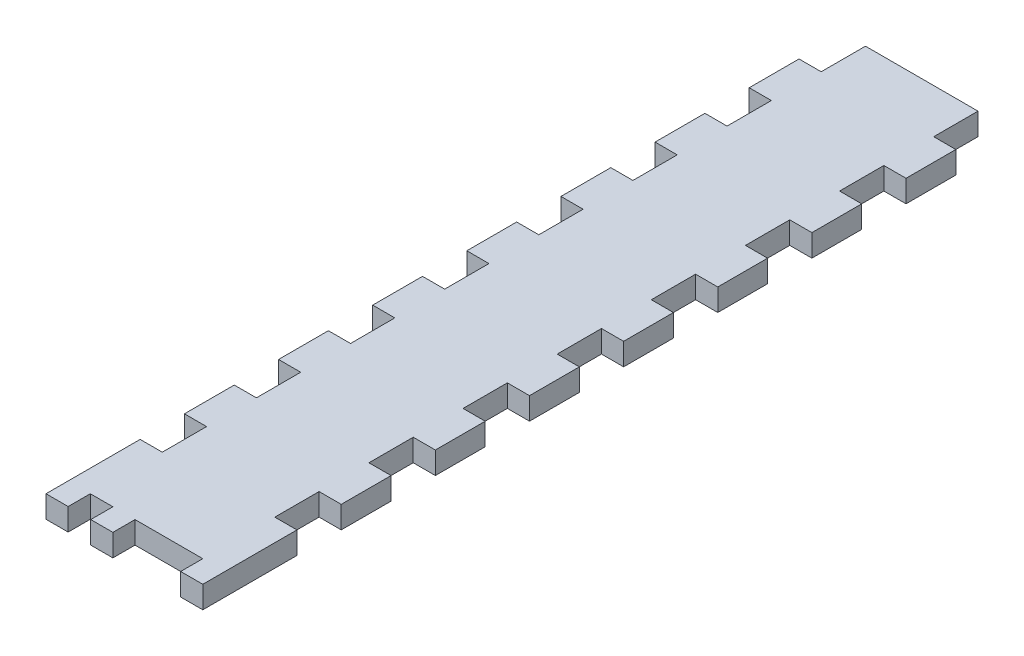
from build123d import *

# Parameters (mm, degrees)
SKETCH1_W           = 44.958
SKETCH1_H           = 304.8
BOSS_EXTRUDE1_DEPTH = 6.35
SKETCH2_W           = 6.35
SKETCH2_H           = 101.6
BOSS_EXTRUDE2_DEPTH = 6.35
SKETCH3_W           = 222.25
SKETCH3_H           = 6.35
BOSS_EXTRUDE3_DEPTH = 38.608
SKETCH7_W           = 333.372738736
SKETCH7_H           = 323.725005723
CUT_EXTRUDE1_DEPTH  = 45.958
SKETCH4_W           = 6.35
SKETCH4_H           = 12.7
CUT_EXTRUDE2_DEPTH  = 6.35
SKETCH8_W           = 6.477
SKETCH8_H           = 6.35
SKETCH8_W_2         = 19.431
CUT_EXTRUDE4_DEPTH  = 7.35


with BuildPart() as part:
    # Sketch1 → Boss-Extrude1 (new body)
    with BuildSketch(Plane.XY):
        with Locations((-6.477, 3.048)):
            Rectangle(SKETCH1_W, SKETCH1_H)
        with BuildLine():
            Line((-3.302, 133.858), (-3.302, -143.002))
            Line((-3.302, -143.002), (3.302, -143.002))
            Line((3.302, -143.002), (3.302, 143.002))
            Line((3.302, 143.002), (-16.256, 143.002))
            Line((-16.256, 143.002), (-16.256, 136.398))
            Line((-16.256, 136.398), (-5.842, 136.398))
            ThreePointArc((-5.842, 136.398), (-4.045948776, 135.654051224), (-3.302, 133.858))
        make_face(mode=Mode.SUBTRACT)
    extrude(amount=BOSS_EXTRUDE1_DEPTH)

    # Sketch2 → Boss-Extrude2 (add)
    with BuildSketch(Plane(origin=(16.002, 0, 0), x_dir=(0, 0, -1), z_dir=(1, 0, 0))):
        Polygon((222.25, -60.452), (222.25, -47.752), (0, -47.752), (0, -149.352), (222.25, -149.352), (222.25, -136.652), (228.6, -136.652), (228.6, -119.718666667), (222.25, -119.718666667), (222.25, -107.018666667), (228.6, -107.018666667), (228.6, -90.085333333), (222.25, -90.085333333), (222.25, -77.385333333), (228.6, -77.385333333), (228.6, -60.452), align=None)
        with BuildLine():
            ThreePointArc((11.4, -116.592), (9.9, -118.092), (8.4, -116.592))
            Line((8.4, -116.592), (8.4, -111.512))
            ThreePointArc((8.4, -111.512), (9.9, -110.012), (11.4, -111.512))
            Line((11.4, -111.512), (11.4, -116.592))
        make_face(mode=Mode.SUBTRACT)
        with BuildLine():
            Line((42.4, -111.512), (42.4, -116.592))
            ThreePointArc((42.4, -116.592), (40.9, -118.092), (39.4, -116.592))
            Line((39.4, -116.592), (39.4, -111.512))
            ThreePointArc((39.4, -111.512), (40.9, -110.012), (42.4, -111.512))
        make_face(mode=Mode.SUBTRACT)
        with BuildLine():
            ThreePointArc((36.4, -101.092), (25.4, -112.092), (14.4, -101.092))
            Line((14.4, -101.092), (14.4, -96.012))
            ThreePointArc((14.4, -96.012), (25.4, -85.012), (36.4, -96.012))
            Line((36.4, -96.012), (36.4, -101.092))
        make_face(mode=Mode.SUBTRACT)
        with BuildLine():
            ThreePointArc((11.4, -85.592), (9.9, -87.092), (8.4, -85.592))
            Line((8.4, -85.592), (8.4, -80.512))
            ThreePointArc((8.4, -80.512), (9.9, -79.012), (11.4, -80.512))
            Line((11.4, -80.512), (11.4, -85.592))
        make_face(mode=Mode.SUBTRACT)
        with BuildLine():
            ThreePointArc((42.4, -85.592), (40.9, -87.092), (39.4, -85.592))
            Line((39.4, -85.592), (39.4, -80.512))
            ThreePointArc((39.4, -80.512), (40.9, -79.012), (42.4, -80.512))
            Line((42.4, -80.512), (42.4, -85.592))
        make_face(mode=Mode.SUBTRACT)
        with Locations((-3.175, -98.552)):
            Rectangle(SKETCH2_W, SKETCH2_H)
    extrude(amount=-BOSS_EXTRUDE2_DEPTH)

    # Sketch3 → Boss-Extrude3 (add)
    with BuildSketch(Plane.ZY.offset(-9.652)):
        with Locations((-111.125, -146.177)):
            Rectangle(SKETCH3_W, SKETCH3_H)
    extrude(amount=BOSS_EXTRUDE3_DEPTH)

    # Sketch7 → Cut-Extrude1 (cut, through all)
    with BuildSketch(Plane(origin=(16.002, 0, 0), x_dir=(0, 0, -1), z_dir=(1, 0, 0))):
        with Locations((160.336369368, 18.860502861)):
            Rectangle(SKETCH7_W, SKETCH7_H)
    extrude(amount=-CUT_EXTRUDE1_DEPTH, mode=Mode.SUBTRACT)

    # Sketch4 → Cut-Extrude2 (cut)
    with BuildSketch(Plane.XZ.offset(149.352)):
        with Locations((12.827, -26.9875)):
            Rectangle(SKETCH4_W, SKETCH4_H)
        with Locations((-25.781, -26.9875)):
            Rectangle(SKETCH4_W, SKETCH4_H)
        with Locations((-25.781, -53.975)):
            Rectangle(SKETCH4_W, SKETCH4_H)
        with Locations((-25.781, -80.9625)):
            Rectangle(SKETCH4_W, SKETCH4_H)
        with Locations((-25.781, -107.95)):
            Rectangle(SKETCH4_W, SKETCH4_H)
        with Locations((-25.781, -134.9375)):
            Rectangle(SKETCH4_W, SKETCH4_H)
        with Locations((-25.781, -161.925)):
            Rectangle(SKETCH4_W, SKETCH4_H)
        with Locations((-25.781, -188.9125)):
            Rectangle(SKETCH4_W, SKETCH4_H)
        with Locations((-25.781, -215.9)):
            Rectangle(SKETCH4_W, SKETCH4_H)
        with Locations((12.827, -215.9)):
            Rectangle(SKETCH4_W, SKETCH4_H)
        with Locations((12.827, -161.925)):
            Rectangle(SKETCH4_W, SKETCH4_H)
        with Locations((12.827, -134.9375)):
            Rectangle(SKETCH4_W, SKETCH4_H)
        with Locations((12.827, -107.95)):
            Rectangle(SKETCH4_W, SKETCH4_H)
        with Locations((12.827, -80.9625)):
            Rectangle(SKETCH4_W, SKETCH4_H)
        with Locations((12.827, -53.975)):
            Rectangle(SKETCH4_W, SKETCH4_H)
        with Locations((12.827, -188.9125)):
            Rectangle(SKETCH4_W, SKETCH4_H)
    extrude(amount=-CUT_EXTRUDE2_DEPTH, mode=Mode.SUBTRACT)

    # Sketch8 → Cut-Extrude4 (cut, through all)
    with BuildSketch(Plane.XZ.offset(149.352)):
        with Locations((-19.3675, 3.175)):
            Rectangle(SKETCH8_W, SKETCH8_H)
        with Locations((-0.0635, 3.175)):
            Rectangle(SKETCH8_W_2, SKETCH8_H)
    extrude(amount=-CUT_EXTRUDE4_DEPTH, mode=Mode.SUBTRACT)


solid = part.part
